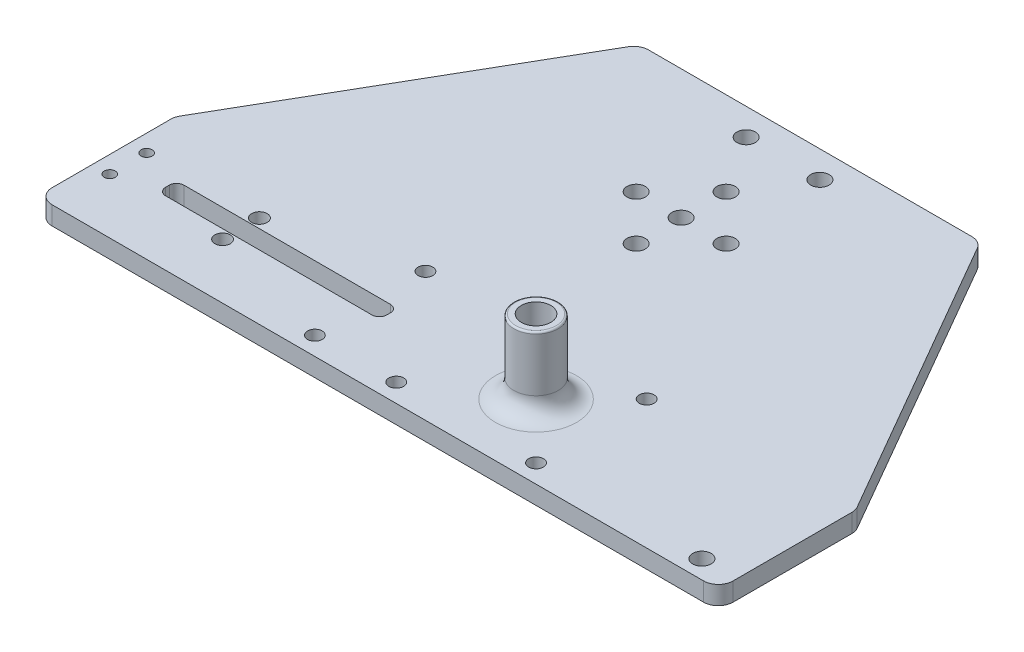
from build123d import *

# Parameters (mm, degrees)
SKETCH1_R                 = 4
BOSS_EXTRUDE1_DEPTH       = 5
SKETCH2_R                 = 6
SKETCH2_R_2               = 4
BOSS_EXTRUDE2_DEPTH       = 20
FILLET1_R                 = 5
FILLET2_R                 = 0.5
SKETCH3_R                 = 2
CUT_EXTRUDE3_DEPTH        = 5
CUT_EXTRUDE8_REACH        = 27
SKETCH10_R                = 2.5
CUT_EXTRUDE10_REACH       = 27
SKETCH13_R                = 1.5
CUT_EXTRUDE11_REACH       = 27
SKETCH14_R                = 2.1
LPATTERN1_COUNT           = 2
LPATTERN1_PITCH           = 12.2
F_4_0MM_DOWEL_HOLE1_D     = 4
F_4_0MM_DOWEL_HOLE1_DEPTH = 5
SKETCH20_R                = 2.5
CUT_EXTRUDE12_DEPTH       = 10


with BuildPart() as part:
    # Sketch1 → Boss-Extrude1 (new body)
    with BuildSketch(Plane(origin=(0, 0, 0), x_dir=(1, 0, 0), z_dir=(0, 1, 0))):
        with BuildLine():
            Line((-96.298040918, -19.992383229), (80.454801266, -20))
            ThreePointArc((80.454801266, -20), (83.283228391, -18.828427125), (84.454801266, -16))
            Line((84.454801266, -16), (84.454801266, 16.211278603))
            ThreePointArc((84.454801266, 16.211278603), (84.318504571, 17.246554783), (83.918902881, 18.211278603))
            Line((83.918902881, 18.211278603), (39.421480269, 95.283075373))
            ThreePointArc((39.421480269, 95.283075373), (37.957378654, 96.747176988), (35.957378654, 97.283075373))
            Line((35.957378654, 97.283075373), (-51.799862263, 97.283075373))
            ThreePointArc((-51.799862263, 97.283075373), (-53.799862263, 96.747176988), (-55.263963878, 95.283075373))
            Line((-55.263963878, 95.283075373), (-99.76138649, 18.211278603))
            ThreePointArc((-99.76138649, 18.211278603), (-100.16098818, 17.246554783), (-100.297284875, 16.211278603))
            Line((-100.297284875, 16.211278603), (-100.297284875, -15.992383301))
            ThreePointArc((-100.297284875, -15.992383301), (-99.125979289, -18.820543111), (-96.298040918, -19.992383229))
        make_face()
        with Locations((15, 0)):
            Circle(SKETCH1_R, mode=Mode.SUBTRACT)
        with BuildLine():
            Line((-27, 2.5), (-83, 2.5))
            ThreePointArc((-83, 2.5), (-84.414213562, 1.914213562), (-85, 0.5))
            Line((-85, 0.5), (-85, -0.5))
            ThreePointArc((-85, -0.5), (-84.414213562, -1.914213562), (-83, -2.5))
            Line((-83, -2.5), (-27, -2.5))
            ThreePointArc((-27, -2.5), (-25.585786438, -1.914213562), (-25, -0.5))
            Line((-25, -0.5), (-25, 0.5))
            ThreePointArc((-25, 0.5), (-25.585786438, 1.914213562), (-27, 2.5))
        make_face(mode=Mode.SUBTRACT)
    extrude(amount=BOSS_EXTRUDE1_DEPTH)

    # Sketch2 → Boss-Extrude2 (add)
    with BuildSketch(Plane(origin=(0, 5, 0), x_dir=(1, 0, 0), z_dir=(0, 1, 0))):
        with Locations((15, 0)):
            Circle(SKETCH2_R)
        with Locations((15, 0)):
            Circle(SKETCH2_R_2, mode=Mode.SUBTRACT)
    extrude(amount=BOSS_EXTRUDE2_DEPTH)

    # Fillet1
    fillet1_edges = [part.edges().sort_by_distance(p)[0] for p in [
        (9, 5, 0),
    ]]
    fillet(fillet1_edges, radius=FILLET1_R)

    # Fillet2
    fillet2_edges = [part.edges().sort_by_distance(p)[0] for p in [
        (9, 25, 0),
    ]]
    fillet(fillet2_edges, radius=FILLET2_R)

    # Sketch3 → Cut-Extrude3 (cut)
    with BuildSketch(Plane(origin=(0, 5, 0), x_dir=(1, 0, 0), z_dir=(0, 1, 0))):
        with Locations((-30, 15)):
            Circle(SKETCH3_R)
        with Locations((-30, -15)):
            Circle(SKETCH3_R)
    cut_extrude3 = extrude(amount=-CUT_EXTRUDE3_DEPTH, mode=Mode.SUBTRACT)

    # Mirror1: Cut-Extrude3 across plane
    add(cut_extrude3.mirror(Plane(origin=(0, 0, 0), x_dir=(0, 0, 1), z_dir=(1, 0, 0))), mode=Mode.SUBTRACT)

    # Sketch10 → Cut-Extrude8 (cut, up to next)
    with BuildSketch(Plane.XZ, mode=Mode.PRIVATE) as cut_extrude8_sk1:
        with Locations((-18, -90)):
            Circle(SKETCH10_R)
    cut_extrude8_tool1 = extrude(cut_extrude8_sk1.sketch, amount=-CUT_EXTRUDE8_REACH, mode=Mode.PRIVATE) & part.part
    add(cut_extrude8_tool1.solids().sort_by_distance((-18, 0, -90))[0], mode=Mode.SUBTRACT)
    # Sketch10 → Cut-Extrude8 (cut, up to next)
    with BuildSketch(Plane.XZ, mode=Mode.PRIVATE) as cut_extrude8_sk2:
        with Locations((2, -90)):
            Circle(SKETCH10_R)
    cut_extrude8_tool2 = extrude(cut_extrude8_sk2.sketch, amount=-CUT_EXTRUDE8_REACH, mode=Mode.PRIVATE) & part.part
    add(cut_extrude8_tool2.solids().sort_by_distance((2, 0, -90))[0], mode=Mode.SUBTRACT)

    # Sketch13 → Cut-Extrude10 (cut, up to next)
    with BuildSketch(Plane(origin=(0, 0, 0), x_dir=(-1, 0, 0), z_dir=(0, -1, 0)), mode=Mode.PRIVATE) as cut_extrude10_sk1:
        with Locations((95.647284875, -4.992383229)):
            Circle(SKETCH13_R)
    cut_extrude10_tool1 = extrude(cut_extrude10_sk1.sketch, amount=-CUT_EXTRUDE10_REACH, mode=Mode.PRIVATE) & part.part
    add(cut_extrude10_tool1.solids().sort_by_distance((-95.647285, 0, 4.992383))[0], mode=Mode.SUBTRACT)
    # Sketch13 → Cut-Extrude10 (cut, up to next)
    with BuildSketch(Plane(origin=(0, 0, 0), x_dir=(-1, 0, 0), z_dir=(0, -1, 0)), mode=Mode.PRIVATE) as cut_extrude10_sk2:
        with Locations((95.647284875, 5.007616771)):
            Circle(SKETCH13_R)
    cut_extrude10_tool2 = extrude(cut_extrude10_sk2.sketch, amount=-CUT_EXTRUDE10_REACH, mode=Mode.PRIVATE) & part.part
    add(cut_extrude10_tool2.solids().sort_by_distance((-95.647285, 0, -5.007617))[0], mode=Mode.SUBTRACT)

    # Sketch14 → Cut-Extrude11 (cut, up to next)
    with BuildSketch(Plane.XZ, mode=Mode.PRIVATE) as cut_extrude11_sk1:
        with Locations((-65.047284875, 4.992383229)):
            Circle(SKETCH14_R)
    cut_extrude11_tool1 = extrude(cut_extrude11_sk1.sketch, amount=-CUT_EXTRUDE11_REACH, mode=Mode.PRIVATE) & part.part
    add(cut_extrude11_tool1.solids().sort_by_distance((-65.047285, 0, 4.992383))[0], mode=Mode.SUBTRACT)
    # Sketch14 → Cut-Extrude11 (cut, up to next)
    with BuildSketch(Plane.XZ, mode=Mode.PRIVATE) as cut_extrude11_sk2:
        with Locations((-65.047284875, -5.007616771)):
            Circle(SKETCH14_R)
    cut_extrude11_tool2 = extrude(cut_extrude11_sk2.sketch, amount=-CUT_EXTRUDE11_REACH, mode=Mode.PRIVATE) & part.part
    add(cut_extrude11_tool2.solids().sort_by_distance((-65.047285, 0, -5.007617))[0], mode=Mode.SUBTRACT)

    # Sketch16 → Ø5.0mm Dowel Hole1 (revolve, cut)
    with BuildSketch(Plane(origin=(-7.921241804, 0, -62.283075373), x_dir=(0, 0, -1), z_dir=(1, 0, 0))):
        Polygon((0, 0), (0, 9.002151548), (2.5, 7.5), (2.5, 0), align=None)
    f_5_0mm_dowel_hole1 = revolve(axis=Axis((-7.921241804, -6.35, -62.283075373), (0, 1, 0)), mode=Mode.SUBTRACT)

    # LPattern1: Ø5.0mm Dowel Hole1 ×2
    with Locations(*[(i * LPATTERN1_PITCH, 0, 0) for i in range(1, LPATTERN1_COUNT)]):
        add(f_5_0mm_dowel_hole1, mode=Mode.SUBTRACT)

    # CirPattern1 copy 1 sketch → CirPattern1 copy 1 (revolve, cut)
    with BuildSketch(Plane(origin=(-7.921241804, 0, -74.483075373), x_dir=(-1, 0, 0), z_dir=(0, 0, -1))):
        Polygon((0, 0), (0, 9.002151548), (2.5, 7.5), (2.5, 0), align=None)
    revolve(axis=Axis((-7.921241804, -6.35, -74.483075373), (0, 1, 0)), mode=Mode.SUBTRACT)

    # CirPattern1 copy 2 sketch → CirPattern1 copy 2 (revolve, cut)
    with BuildSketch(Plane(origin=(-20.121241804, 0, -62.283075373), x_dir=(0, 0, 1), z_dir=(-1, 0, 0))):
        Polygon((0, 0), (0, 9.002151548), (2.5, 7.5), (2.5, 0), align=None)
    revolve(axis=Axis((-20.121241804, -6.35, -62.283075373), (0, 1, 0)), mode=Mode.SUBTRACT)

    # CirPattern1 copy 3 sketch → CirPattern1 copy 3 (revolve, cut)
    with BuildSketch(Plane(origin=(-7.921241804, 0, -50.083075373), x_dir=(1, 0, 0), z_dir=(0, 0, 1))):
        Polygon((0, 0), (0, 9.002151548), (2.5, 7.5), (2.5, 0), align=None)
    revolve(axis=Axis((-7.921241804, -6.35, -50.083075373), (0, 1, 0)), mode=Mode.SUBTRACT)

    # CirPattern1 copy 4 sketch → CirPattern1 copy 4 (revolve, cut)
    with BuildSketch(Plane(origin=(-7.921241804, 0, -62.283075373), x_dir=(-1, 0, 0), z_dir=(0, 0, -1))):
        Polygon((0, 0), (0, 9.002151548), (2.5, 7.5), (2.5, 0), align=None)
    revolve(axis=Axis((-7.921241804, -6.35, -62.283075373), (0, 1, 0)), mode=Mode.SUBTRACT)

    # CirPattern1 copy 5 sketch → CirPattern1 copy 5 (revolve, cut)
    with BuildSketch(Plane(origin=(-7.921241804, 0, -62.283075373), x_dir=(0, 0, 1), z_dir=(-1, 0, 0))):
        Polygon((0, 0), (0, 9.002151548), (2.5, 7.5), (2.5, 0), align=None)
    revolve(axis=Axis((-7.921241804, -6.35, -62.283075373), (0, 1, 0)), mode=Mode.SUBTRACT)

    # CirPattern1 copy 6 sketch → CirPattern1 copy 6 (revolve, cut)
    with BuildSketch(Plane(origin=(-7.921241804, 0, -62.283075373), x_dir=(1, 0, 0), z_dir=(0, 0, 1))):
        Polygon((0, 0), (0, 9.002151548), (2.5, 7.5), (2.5, 0), align=None)
    revolve(axis=Axis((-7.921241804, -6.35, -62.283075373), (0, 1, 0)), mode=Mode.SUBTRACT)

    # Ø4.0mm Dowel Hole1
    with Locations(Plane(origin=(0, 5, 0), x_dir=(1, 0, 0), z_dir=(0, 1, 0))):
        with Locations((-7.922284875, -14.996191581)):
            Hole(F_4_0MM_DOWEL_HOLE1_D / 2, depth=F_4_0MM_DOWEL_HOLE1_DEPTH)

    # Sketch20 → Cut-Extrude12 (cut)
    with BuildSketch(Plane(origin=(0, 5, 0), x_dir=(1, 0, 0), z_dir=(0, 1, 0))):
        with Locations((75, -15)):
            Circle(SKETCH20_R)
    extrude(amount=-CUT_EXTRUDE12_DEPTH, mode=Mode.SUBTRACT)


solid = part.part
